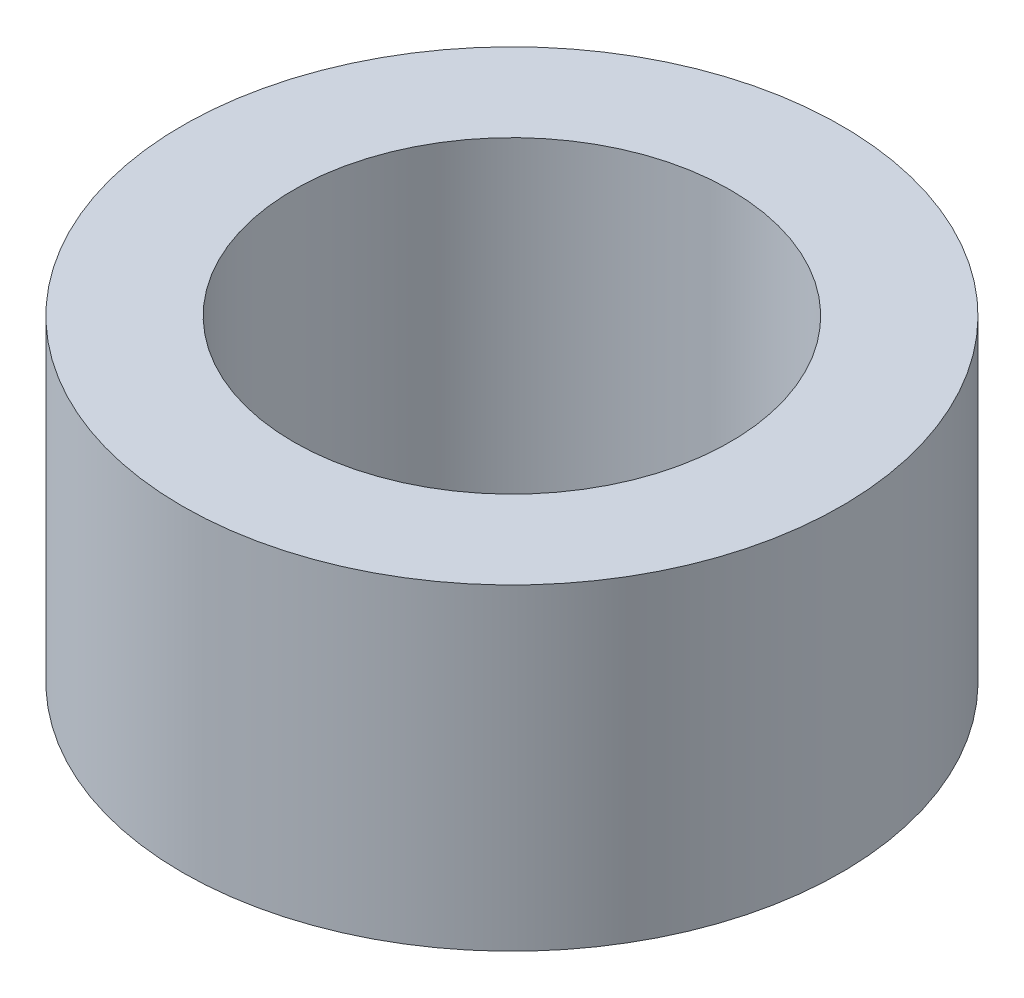
from build123d import *

# Parameters (mm, degrees)
SKETCH1_R           = 4
SKETCH1_R_2         = 2.65
BOSS_EXTRUDE1_DEPTH = 3.85


with BuildPart() as part:
    # Sketch1 → Boss-Extrude1 (new body)
    with BuildSketch(Plane(origin=(0, 0, 0), x_dir=(1, 0, 0), z_dir=(0, 1, 0))):
        Circle(SKETCH1_R)
        Circle(SKETCH1_R_2, mode=Mode.SUBTRACT)
    extrude(amount=BOSS_EXTRUDE1_DEPTH)


solid = part.part
